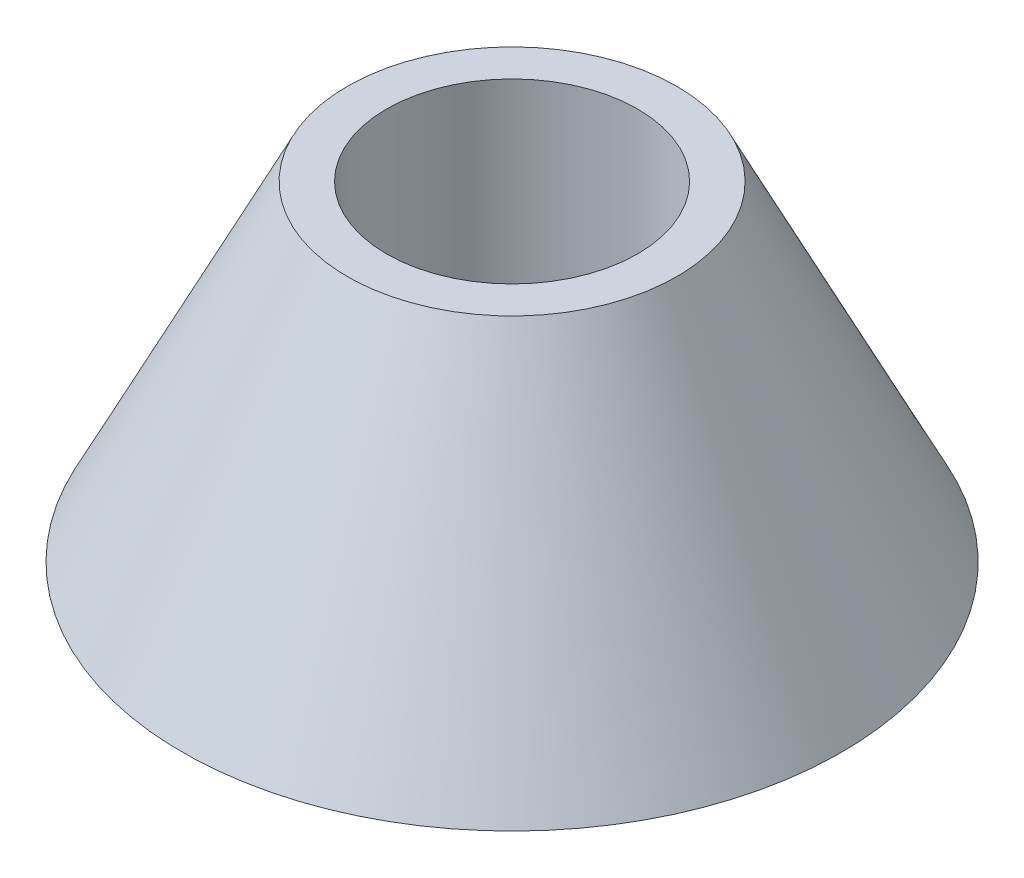
from build123d import *


with BuildPart() as part:
    # Esboço1 → Revolução1 (revolve)
    with BuildSketch(Plane.XY):
        Polygon((19.05, 50), (25, 50), (50, 0), (0, 0), (0, 10), (19.05, 10), align=None)
    revolve(axis=Axis((0, 0, 0), (0, 1, 0)))


solid = part.part
